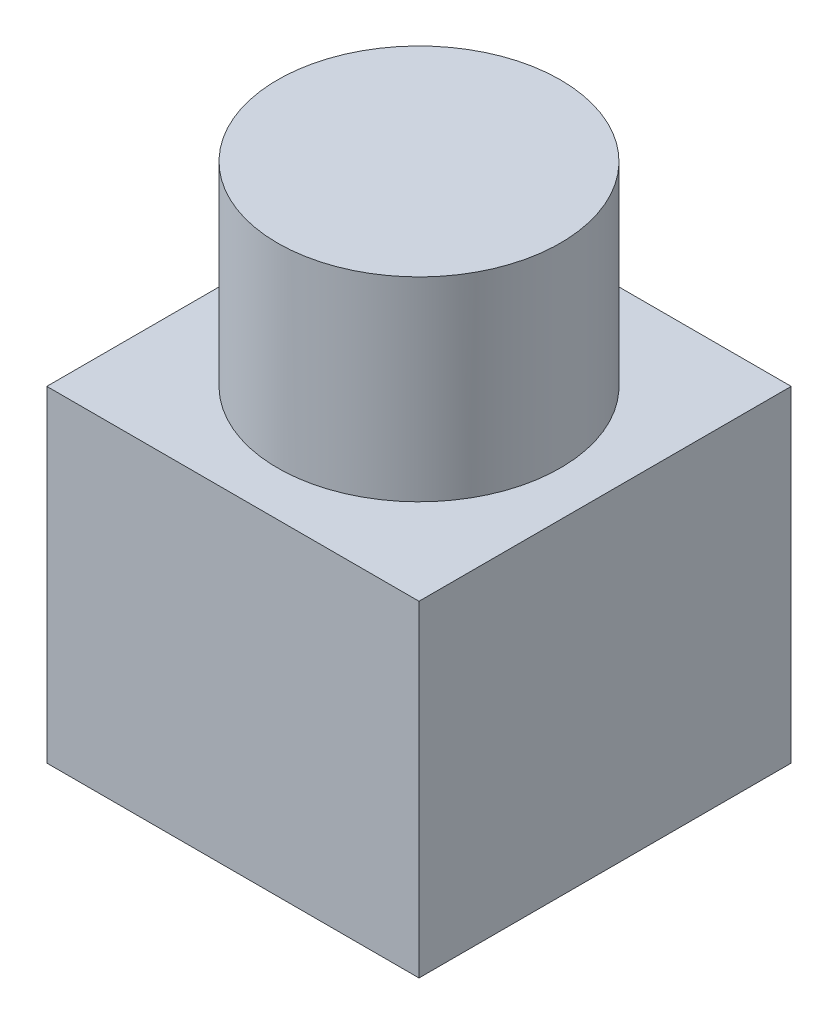
from build123d import *

# Parameters (mm, degrees)
SKETCH2_W           = 76.2
SKETCH2_H           = 76.2
BOSS_EXTRUDE1_DEPTH = 66.802
SKETCH3_R           = 28.956
BOSS_EXTRUDE2_DEPTH = 39.878


with BuildPart() as part:
    # Sketch2 → Boss-Extrude1 (new body)
    with BuildSketch(Plane(origin=(0, 0, 0), x_dir=(1, 0, 0), z_dir=(0, 1, 0))):
        Rectangle(SKETCH2_W, SKETCH2_H)
    extrude(amount=BOSS_EXTRUDE1_DEPTH)

    # Sketch3 → Boss-Extrude2 (add)
    with BuildSketch(Plane(origin=(0, 66.802, 0), x_dir=(1, 0, 0), z_dir=(0, 1, 0))):
        Circle(SKETCH3_R)
    extrude(amount=BOSS_EXTRUDE2_DEPTH)


solid = part.part
